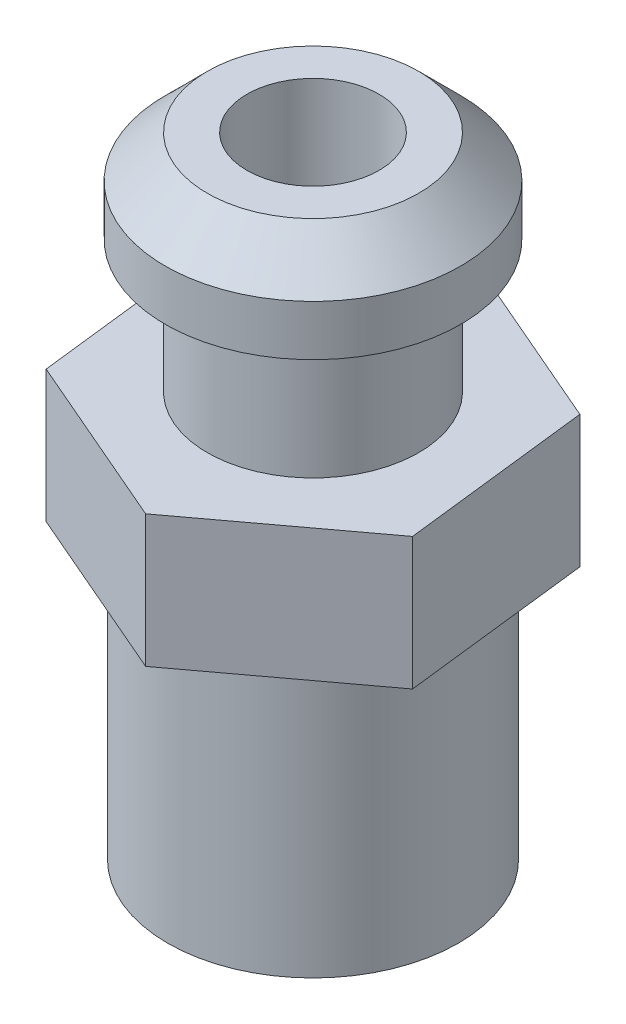
from build123d import *

# Parameters (mm, degrees)
SKETCH2_OUTSIDE_W  = 15.626
SKETCH2_OUTSIDE_H  = 15.626
CUT_EXTRUDE1_DEPTH = 2.54
SKETCH3_R          = 1.27
CUT_EXTRUDE2_DEPTH = 11.43
SKETCH4_R          = 0.635
CUT_EXTRUDE3_DEPTH = 11.43


with BuildPart() as part:
    # Sketch1 → Revolve2 (revolve)
    with BuildSketch(Plane(origin=(0, 0, 0), x_dir=(0, 0, -1), z_dir=(1, 0, 0))):
        Polygon((0, 0), (0, 13.716), (2.032, 13.716), (2.839757444, 12.908242556), (2.839757444, 11.938), (2.032, 11.938), (2.032, 9.398), (4.868925194, 9.398), (4.868925194, 6.858), (2.794, 6.858), (2.794, 1.613116652), align=None)
    revolve(axis=Axis((0, 0, 0), (0, 1, 0)))

    # Sketch2 outside → Cut-Extrude1 (cut)
    with BuildSketch(Plane(origin=(0, 9.398, 0), x_dir=(1, 0, 0), z_dir=(0, 1, 0))):
        Rectangle(SKETCH2_OUTSIDE_W, SKETCH2_OUTSIDE_H)
        Polygon((3.366014334, -1.452852654), (2.941214474, 2.188627596), (-0.424799861, 3.64148025), (-3.366014334, 1.452852654), (-2.941214474, -2.188627596), (0.424799861, -3.64148025), align=None, mode=Mode.SUBTRACT)
    extrude(amount=-CUT_EXTRUDE1_DEPTH, mode=Mode.SUBTRACT)

    # Sketch3 → Cut-Extrude2 (cut)
    with BuildSketch(Plane(origin=(0, 13.716, 0), x_dir=(1, 0, 0), z_dir=(0, 1, 0))):
        Circle(SKETCH3_R)
    extrude(amount=-CUT_EXTRUDE2_DEPTH, mode=Mode.SUBTRACT)

    # Sketch4 → Cut-Extrude3 (cut)
    with BuildSketch(Plane(origin=(0, 0, 0), x_dir=(0, 0, -1), z_dir=(1, 0, 0))):
        with Locations((0, 3.79195236)):
            Circle(SKETCH4_R)
    extrude(amount=-CUT_EXTRUDE3_DEPTH, mode=Mode.SUBTRACT)


solid = part.part
